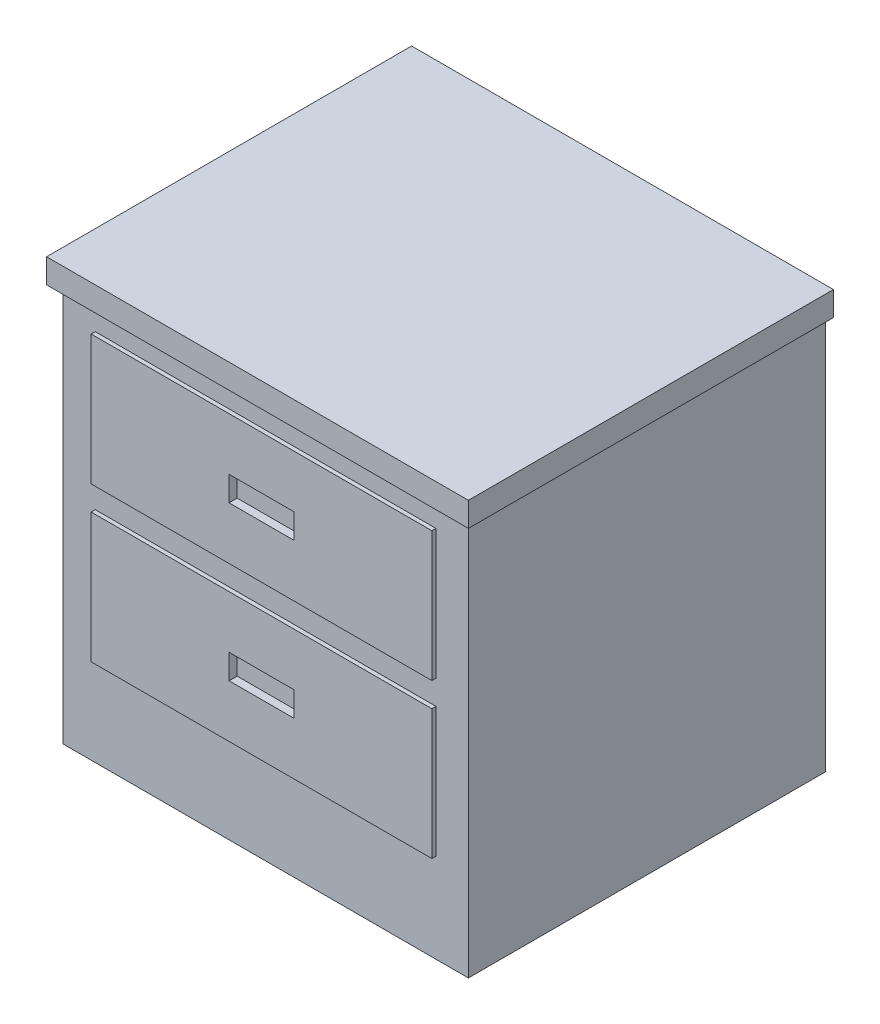
from build123d import *

# Parameters (mm, degrees)
SKETCH_1_W             = 500
SKETCH_1_H             = 440
EXTRUDE_1_DEPTH        = 520
SKETCH_2_W             = 520
SKETCH_2_H             = 450
EXTRUDE_2_DEPTH        = 30
SKETCH_3_W             = 420
SKETCH_3_H             = 160
EXTRUDE_3_DEPTH        = 5
SKETCH_4_W             = 80
SKETCH_4_H             = 30.476190476
CUT_EXTRUDE_2_DEPTH    = 10
PATTERN_LINEAR_1_COUNT = 2
PATTERN_LINEAR_1_PITCH = 190


with BuildPart() as part:
    # 草图1 → 凸台-拉伸1 (new body)
    with BuildSketch(Plane(origin=(0, 0, 0), x_dir=(1, 0, 0), z_dir=(0, 1, 0))):
        Rectangle(SKETCH_1_W, SKETCH_1_H)
    extrude(amount=EXTRUDE_1_DEPTH)

    # 草图2 → 凸台-拉伸2 (add)
    with BuildSketch(Plane(origin=(0, 520, 0), x_dir=(1, 0, 0), z_dir=(0, 1, 0))):
        with Locations((0, -5)):
            Rectangle(SKETCH_2_W, SKETCH_2_H)
    extrude(amount=-EXTRUDE_2_DEPTH)

    # 草图3 → 凸台-拉伸3 (add)
    with BuildSketch(Plane.XY.offset(220)):
        with Locations((0, 380)):
            Rectangle(SKETCH_3_W, SKETCH_3_H)
    extrude_3 = extrude(amount=EXTRUDE_3_DEPTH)

    # 草图4 → 切除-拉伸2 (cut)
    with BuildSketch(Plane.XY.offset(225)):
        with Locations((0, 380)):
            Rectangle(SKETCH_4_W, SKETCH_4_H)
    cut_extrude_2 = extrude(amount=-CUT_EXTRUDE_2_DEPTH, mode=Mode.SUBTRACT)

    # 阵列(线性)1: 凸台-拉伸3, 切除-拉伸2 ×2
    with Locations(*[(0, -i * PATTERN_LINEAR_1_PITCH, 0) for i in range(1, PATTERN_LINEAR_1_COUNT)]):
        add(extrude_3)
        add(cut_extrude_2, mode=Mode.SUBTRACT)


solid = part.part
